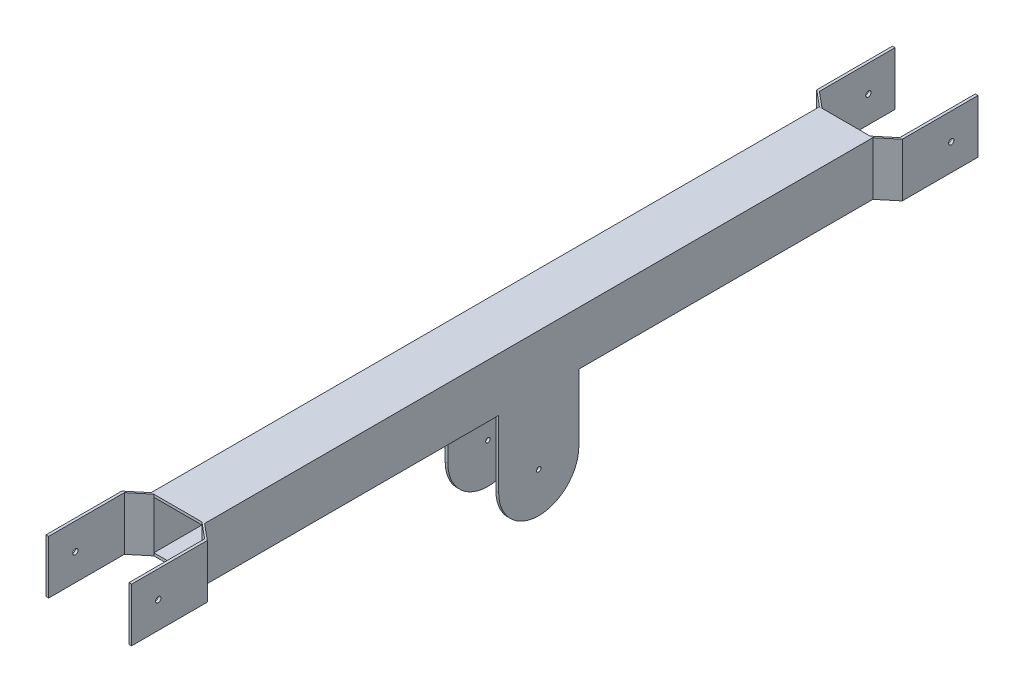
from build123d import *

# Parameters (mm, degrees)
IZIM1_W                       = 120
IZIM1_H                       = 120
IZIM1_W_2                     = 108
IZIM1_H_2                     = 108
Y_KSEKLIK_EKSTR_ZYON1_DEPTH   = 1700
Y_KSEKLIK_EKSTR_ZYON2_DEPTH   = 120
Y_KSEKLIK_EKSTR_ZYON2_2_DEPTH = 120
IZIM3_R                       = 6
KES_EKSTR_ZYON3_DEPTH         = 264
IZIM4_W                       = 120
IZIM4_H                       = 200
KES_EKSTR_ZYON4_DEPTH         = 184
Y_KSEKLIK_EKSTR_ZYON3_DEPTH   = 6
Y_KSEKLIK_EKSTR_ZYON4_DEPTH   = 6
IZIM8_R                       = 5
KES_EKSTR_ZYON5_DEPTH         = 181


with BuildPart() as part:
    # Çizim1 → Yükseklik-Ekstrüzyon1 (new body)
    with BuildSketch(Plane.XY):
        with Locations((60, 60)):
            Rectangle(IZIM1_W, IZIM1_H)
        with Locations((60, 60)):
            Rectangle(IZIM1_W_2, IZIM1_H_2, mode=Mode.SUBTRACT)
    extrude(amount=-Y_KSEKLIK_EKSTR_ZYON1_DEPTH)

    # Çizim4 → Kes-Ekstrüzyon4 (cut)
    with BuildSketch(Plane(origin=(0, 120, 0), x_dir=(1, 0, 0), z_dir=(0, 1, 0))):
        with Locations((60, 100)):
            Rectangle(IZIM4_W, IZIM4_H)
    extrude(amount=-KES_EKSTR_ZYON4_DEPTH, mode=Mode.SUBTRACT)


with BuildPart() as body_2:
    # Çizim2 → Yükseklik-Ekstrüzyon2 (new body)
    with BuildSketch(Plane(origin=(0, 120, 0), x_dir=(1, 0, 0), z_dir=(0, 1, 0))):
        Polygon((0, 1700), (-36, 1730), (-36, 1900), (-30, 1900), (-30, 1730), (6, 1700), align=None)
    y_kseklik_ekstr_zyon2 = extrude(amount=-Y_KSEKLIK_EKSTR_ZYON2_DEPTH)


with BuildPart() as body_3:
    # Çizim2 → Y_kseklik-Ekstr_zyon2 2 (new body)
    with BuildSketch(Plane(origin=(0, 120, 0), x_dir=(1, 0, 0), z_dir=(0, 1, 0))):
        Polygon((150, 1900), (156, 1900), (156, 1730), (120, 1700), (114, 1700), (150, 1730), align=None)
    y_kseklik_ekstr_zyon2_2 = extrude(amount=-Y_KSEKLIK_EKSTR_ZYON2_2_DEPTH)


with BuildPart() as kes_ekstr_zyon3_tool:
    # Çizim3 → Kes-Ekstrüzyon3 (new body)
    with BuildSketch(Plane(origin=(156, 0, 0), x_dir=(0, 0, -1), z_dir=(1, 0, 0))):
        with Locations((1840, 60)):
            Circle(IZIM3_R)
    kes_ekstr_zyon3 = extrude(amount=-KES_EKSTR_ZYON3_DEPTH)


with BuildPart() as body_2_1:
    add(body_2.part)

    # Kes-Ekstrüzyon3: cut by kes_ekstr_zyon3_tool
    add(kes_ekstr_zyon3_tool.part, mode=Mode.SUBTRACT)


with BuildPart() as body_3_1:
    add(body_3.part)

    # Kes-Ekstrüzyon3: cut by kes_ekstr_zyon3_tool
    add(kes_ekstr_zyon3_tool.part, mode=Mode.SUBTRACT)


with BuildPart() as part_1:
    add(part.part)

    # Aynalama1: Yükseklik-Ekstrüzyon2, Y_kseklik-Ekstr_zyon2 2 across plane
    add(y_kseklik_ekstr_zyon2.mirror(Plane.XY.offset(-950)))
    add(y_kseklik_ekstr_zyon2_2.mirror(Plane.XY.offset(-950)))

    # Aynalama2: Kes-Ekstrüzyon3 across plane
    add(kes_ekstr_zyon3.mirror(Plane.XY.offset(-950)), mode=Mode.SUBTRACT)

    # Çizim6 → Yükseklik-Ekstrüzyon3 (add)
    with BuildSketch(Plane(origin=(120, 0, 0), x_dir=(0, 0, -1), z_dir=(1, 0, 0))):
        with BuildLine():
            Line((860, 0), (860, -150))
            ThreePointArc((860, -150), (950, -240), (1040, -150))
            Line((1040, -150), (1040, 0))
            Line((1040, 0), (860, 0))
        make_face()
    extrude(amount=-Y_KSEKLIK_EKSTR_ZYON3_DEPTH)

    # Çizim7 → Yükseklik-Ekstrüzyon4 (add)
    with BuildSketch(Plane.ZY):
        with BuildLine():
            Line((-1040, 0), (-860, 0))
            Line((-860, 0), (-860, -150))
            ThreePointArc((-860, -150), (-950, -240), (-1040, -150))
            Line((-1040, -150), (-1040, 0))
        make_face()
    extrude(amount=-Y_KSEKLIK_EKSTR_ZYON4_DEPTH)

    # Çizim8 → Kes-Ekstrüzyon5 (cut)
    with BuildSketch(Plane(origin=(120, 0, 0), x_dir=(0, 0, -1), z_dir=(1, 0, 0))):
        with Locations((950, -150)):
            Circle(IZIM8_R)
    extrude(amount=-KES_EKSTR_ZYON5_DEPTH, mode=Mode.SUBTRACT)


solid = Compound([body_2_1.part, body_3_1.part, part_1.part])
